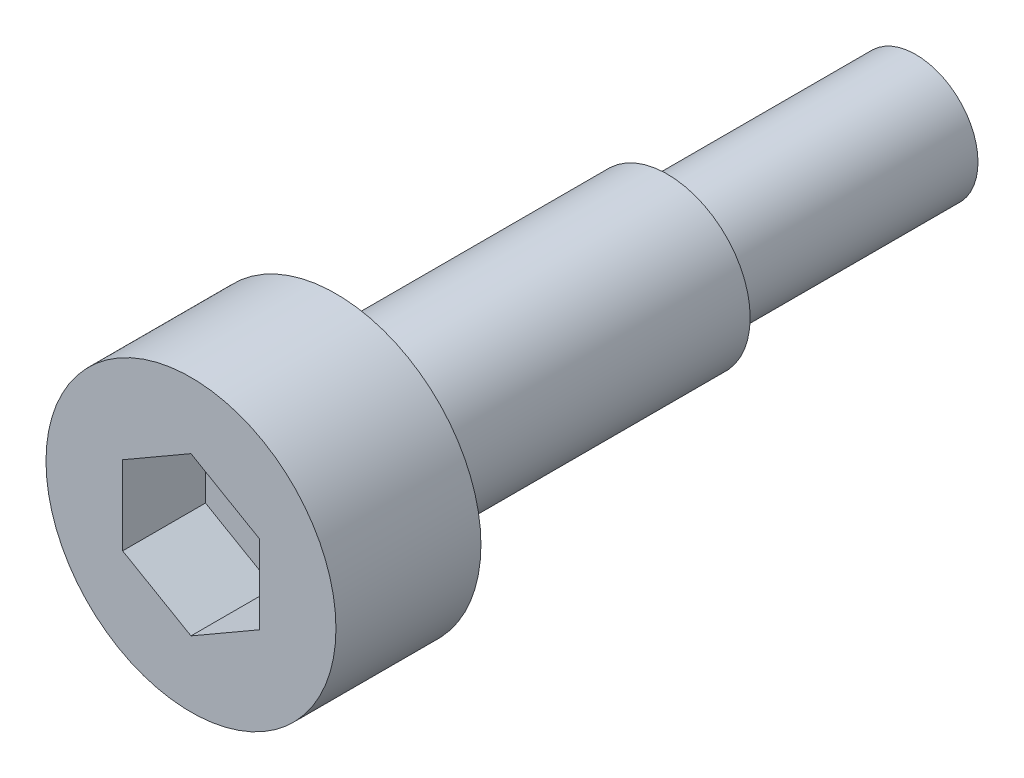
from build123d import *

# Parameters (mm, degrees)
SKETCH_1_R          = 1.5
EXTRUDE_1_DEPTH     = 6
SKETCH_2_R          = 2
EXTRUDE_2_DEPTH     = 8
SKETCH_3_R          = 3.5
EXTRUDE_3_DEPTH     = 3.5
CUT_EXTRUDE_1_DEPTH = 2


with BuildPart() as part:
    # 草图1 → 凸台-拉伸1 (new body)
    with BuildSketch(Plane.XY):
        Circle(SKETCH_1_R)
    extrude(amount=EXTRUDE_1_DEPTH)

    # 草图2 → 凸台-拉伸2 (add)
    with BuildSketch(Plane.XY.offset(6)):
        Circle(SKETCH_2_R)
    extrude(amount=EXTRUDE_2_DEPTH)

    # 草图3 → 凸台-拉伸3 (add)
    with BuildSketch(Plane.XY.offset(14)):
        Circle(SKETCH_3_R)
    extrude(amount=EXTRUDE_3_DEPTH)

    # 草图4 → 切除-拉伸1 (cut)
    with BuildSketch(Plane.XY.offset(17.5)):
        Polygon((0, 1.905255888), (-1.65, 0.952627944), (-1.65, -0.952627944), (0, -1.905255888), (1.65, -0.952627944), (1.65, 0.952627944), align=None)
    extrude(amount=-CUT_EXTRUDE_1_DEPTH, mode=Mode.SUBTRACT)


solid = part.part
